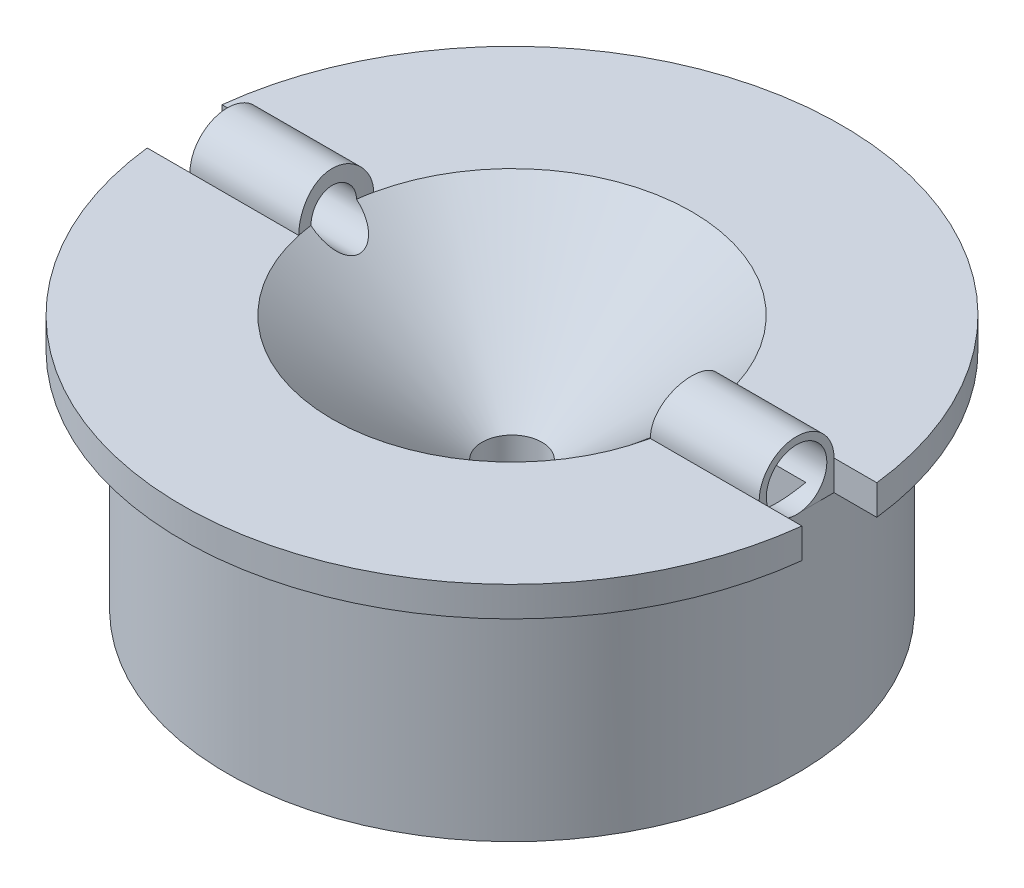
from build123d import *

# Parameters (mm, degrees)
SKETCH2_W               = 7
SKETCH2_H               = 2.5
REVOLVE2_ANGLE          = 180
BOSS_EXTRUDE4_DEPTH     = 24
CUT_EXTRUDE1_DEPTH      = 3.5
SKETCH17_W              = 3
SKETCH17_H              = 5
CUT_EXTRUDE6_DEPTH      = 18
SKETCH16_R              = 1.52
CUT_EXTRUDE5_DEPTH      = 3.857492994
CUT_EXTRUDE5_DEPTH_BACK = 41.857492994
SKETCH19_R              = 2.02
CUT_EXTRUDE7_DEPTH      = 3
SKETCH20_R              = 2.02
CUT_EXTRUDE8_DEPTH      = 3
SKETCH21_R              = 15
CUT_EXTRUDE9_DEPTH      = 6.5
SKETCH22_R              = 5
BOSS_EXTRUDE6_DEPTH     = 6.5
SKETCH23_W              = 2
SKETCH23_H              = 3
SKETCH24_W              = 2
SKETCH24_H              = 3
SKETCH25_R              = 2
CUT_EXTRUDE11_DEPTH     = 20.5000001
SKETCH26_R              = 3.17
CUT_EXTRUDE12_DEPTH     = 6.5


with BuildPart() as part:
    # Sketch1 → Revolve1 (revolve)
    with BuildSketch(Plane.XY):
        Polygon((0, 0), (12, 10), (17, 10), (22, 10), (22, 8), (19, 8), (19, -7), (0, -7), align=None)
    revolve(axis=Axis((0, -7, 0), (0, 1, 0)))

    # Sketch2 → Revolve2 (revolve)
    with BuildSketch(Plane(origin=(0, 10, 0), x_dir=(1, 0, 0), z_dir=(0, 1, 0))):
        with Locations((15.5, 1.25)):
            Rectangle(SKETCH2_W, SKETCH2_H)
        with Locations((-15.5, 1.25)):
            Rectangle(SKETCH2_W, SKETCH2_H)
    revolve(axis=Axis((0, 10, 0), (1, 0, 0)), revolution_arc=REVOLVE2_ANGLE)

    # Sketch8 → Boss-Extrude4 (add)
    with BuildSketch(Plane(origin=(-12, 0, 0), x_dir=(0, 0, -1), z_dir=(1, 0, 0))):
        with BuildLine():
            Line((-2.5, 10), (0, 10))
            Line((0, 10), (2.5, 10))
            ThreePointArc((2.5, 10), (0, 12.5), (-2.5, 10))
        make_face()
    extrude(amount=BOSS_EXTRUDE4_DEPTH)

    # Sketch9 → Cut-Extrude1 (cut, through all)
    with BuildSketch(Plane(origin=(0, 10, 0), x_dir=(1, 0, 0), z_dir=(0, 1, 0))):
        with BuildLine():
            ThreePointArc((-11.736694594, 2.5), (-12, 0), (-11.736694594, -2.5))
            ThreePointArc((-11.736694594, -2.5), (0, -12), (11.736694594, -2.5))
            ThreePointArc((11.736694594, -2.5), (12, 0), (11.736694594, 2.5))
            ThreePointArc((11.736694594, 2.5), (0, 12), (-11.736694594, 2.5))
        make_face()
    extrude(amount=CUT_EXTRUDE1_DEPTH, mode=Mode.SUBTRACT)

    # Sketch17 → Cut-Extrude6 (cut, through all)
    with BuildSketch(Plane(origin=(0, 10, 0), x_dir=(1, 0, 0), z_dir=(0, 1, 0))):
        with Locations((20.5, 0)):
            Rectangle(SKETCH17_W, SKETCH17_H)
        with Locations((-20.5, 0)):
            Rectangle(SKETCH17_W, SKETCH17_H)
    extrude(amount=-CUT_EXTRUDE6_DEPTH, mode=Mode.SUBTRACT)

    # Sketch16 → Cut-Extrude5 (cut, two sides)
    with BuildSketch(Plane.ZY.offset(19)) as cut_extrude5_sk:
        with Locations((0, 10)):
            Circle(SKETCH16_R)
    extrude(amount=CUT_EXTRUDE5_DEPTH, mode=Mode.SUBTRACT)
    extrude(cut_extrude5_sk.sketch, amount=-CUT_EXTRUDE5_DEPTH_BACK, mode=Mode.SUBTRACT)

    # Sketch19 → Cut-Extrude7 (cut)
    with BuildSketch(Plane.ZY.offset(19)):
        with Locations((0, 10)):
            Circle(SKETCH19_R)
    extrude(amount=-CUT_EXTRUDE7_DEPTH, mode=Mode.SUBTRACT)

    # Sketch20 → Cut-Extrude8 (cut)
    with BuildSketch(Plane(origin=(19, 0, 0), x_dir=(0, 0, -1), z_dir=(1, 0, 0))):
        with Locations((0, 10)):
            Circle(SKETCH20_R)
    extrude(amount=-CUT_EXTRUDE8_DEPTH, mode=Mode.SUBTRACT)

    # Sketch21 → Cut-Extrude9 (cut)
    with BuildSketch(Plane.XZ.offset(7)):
        Circle(SKETCH21_R)
    extrude(amount=-CUT_EXTRUDE9_DEPTH, mode=Mode.SUBTRACT)

    # Sketch22 → Boss-Extrude6 (add)
    with BuildSketch(Plane.XZ.offset(0.5)):
        Circle(SKETCH22_R)
    extrude(amount=BOSS_EXTRUDE6_DEPTH)

    # Cut-Sweep2: sweep along a curve in space
    with BuildLine() as cut_sweep2_path:
        Line((10, -0.5, 0), (16, 8.48, 0))
        Line((16, 8.48, 0), (16.813206723, 9.697099395, 0))
    # Sketch23 → Cut-Sweep2 (sweep, cut)
    with BuildSketch(Plane.XZ.offset(0.5)):
        with Locations((11, 0)):
            Rectangle(SKETCH23_W, SKETCH23_H)
    sweep(path=cut_sweep2_path.line, mode=Mode.SUBTRACT)

    # Cut-Sweep3: sweep along a curve in space
    with BuildLine() as cut_sweep3_path:
        Line((-10, -0.5, 0), (-16, 8.48, 0))
        Line((-16, 8.48, 0), (-16.813206723, 9.697099395, 0))
    # Sketch24 → Cut-Sweep3 (sweep, cut)
    with BuildSketch(Plane.XZ.offset(0.5)):
        with Locations((-11, 0)):
            Rectangle(SKETCH24_W, SKETCH24_H)
    sweep(path=cut_sweep3_path.line, mode=Mode.SUBTRACT)

    # Sketch25 → Cut-Extrude11 (cut, through all)
    with BuildSketch(Plane.XZ.offset(7)):
        Circle(SKETCH25_R)
    extrude(amount=-CUT_EXTRUDE11_DEPTH, mode=Mode.SUBTRACT)

    # Sketch26 → Cut-Extrude12 (cut)
    with BuildSketch(Plane.XZ.offset(7)):
        Circle(SKETCH26_R)
    extrude(amount=-CUT_EXTRUDE12_DEPTH, mode=Mode.SUBTRACT)


solid = part.part
